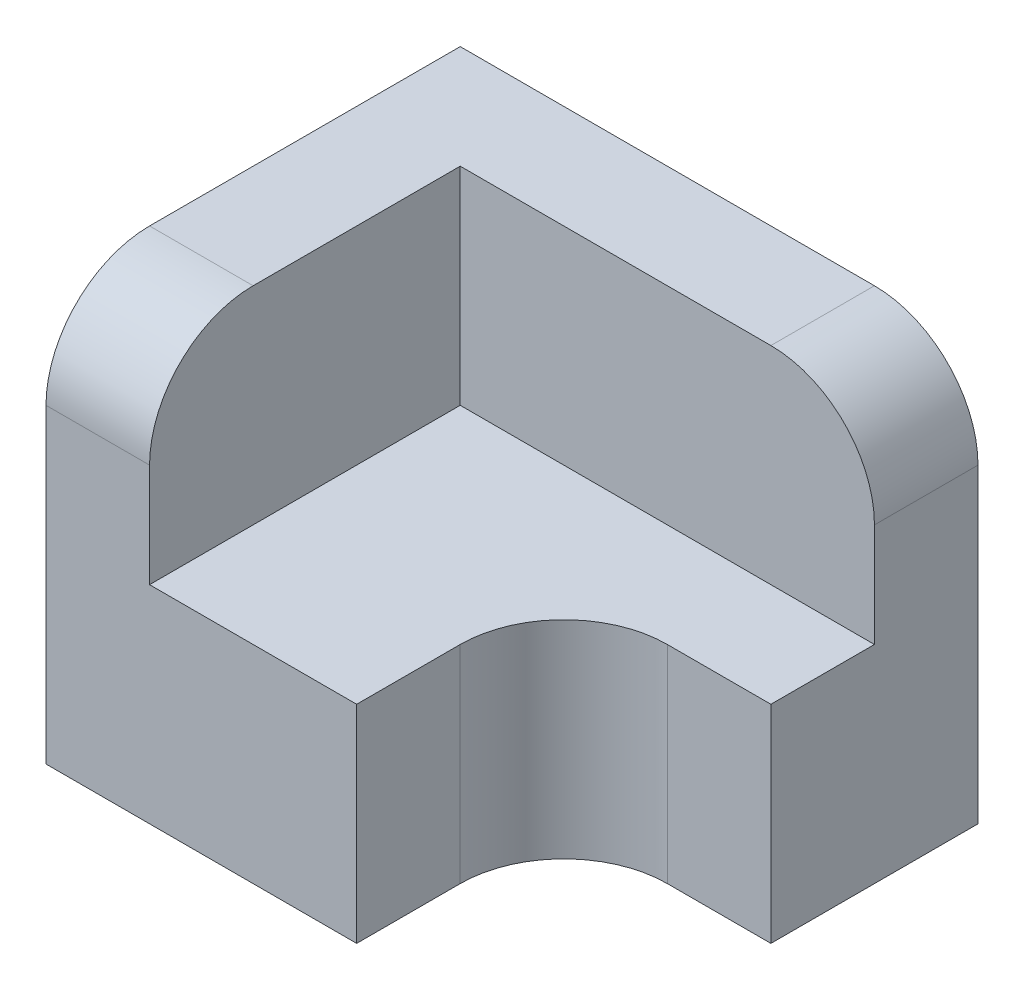
from build123d import *

# Parameters (mm, degrees)
EXTRUDE_1_DEPTH = 10
EXTRUDE_2_DEPTH = 20
FILLET_1_R      = 5
SCALE_1_SCALE   = 0.2


with BuildPart() as part:
    # 草圖1 → 填料-伸長1 (new body)
    with BuildSketch(Plane(origin=(0, 0, 0), x_dir=(1, 0, 0), z_dir=(0, 1, 0))):
        with BuildLine():
            Line((-12.5, -10), (2.5, -10))
            Line((2.5, -10), (2.5, -5))
            ThreePointArc((2.5, -5), (3.964466094, -1.464466094), (7.5, 0))
            Line((7.5, 0), (12.5, 0))
            Line((12.5, 0), (12.5, 10))
            Line((12.5, 10), (-12.5, 10))
            Line((-12.5, 10), (-12.5, -10))
        make_face()
    extrude(amount=EXTRUDE_1_DEPTH)

    # 草圖1<3> → 填料-伸長2 (add)
    with BuildSketch(Plane(origin=(0, 0, 0), x_dir=(1, 0, 0), z_dir=(0, 1, 0))):
        Polygon((-12.5, 5), (-12.5, -10), (-7.5, -10), (-7.5, 5), (12.5, 5), (12.5, 10), (-7.5, 10), (-12.5, 10), align=None)
    extrude(amount=EXTRUDE_2_DEPTH)

    # 圓角1
    fillet_1_edges = [part.edges().sort_by_distance(p)[0] for p in [
        (-10, 20, 10),
        (12.5, 20, -7.5),
    ]]
    fillet(fillet_1_edges, radius=FILLET_1_R)


with BuildPart() as part_1:
    # 縮放比例1: scaled about (-2.47384308, 8.209193679, -2.079530772)
    add(part.part.scale(SCALE_1_SCALE).moved(Location((-1.979074464, 6.567354943, -1.663624618))))


solid = part_1.part
